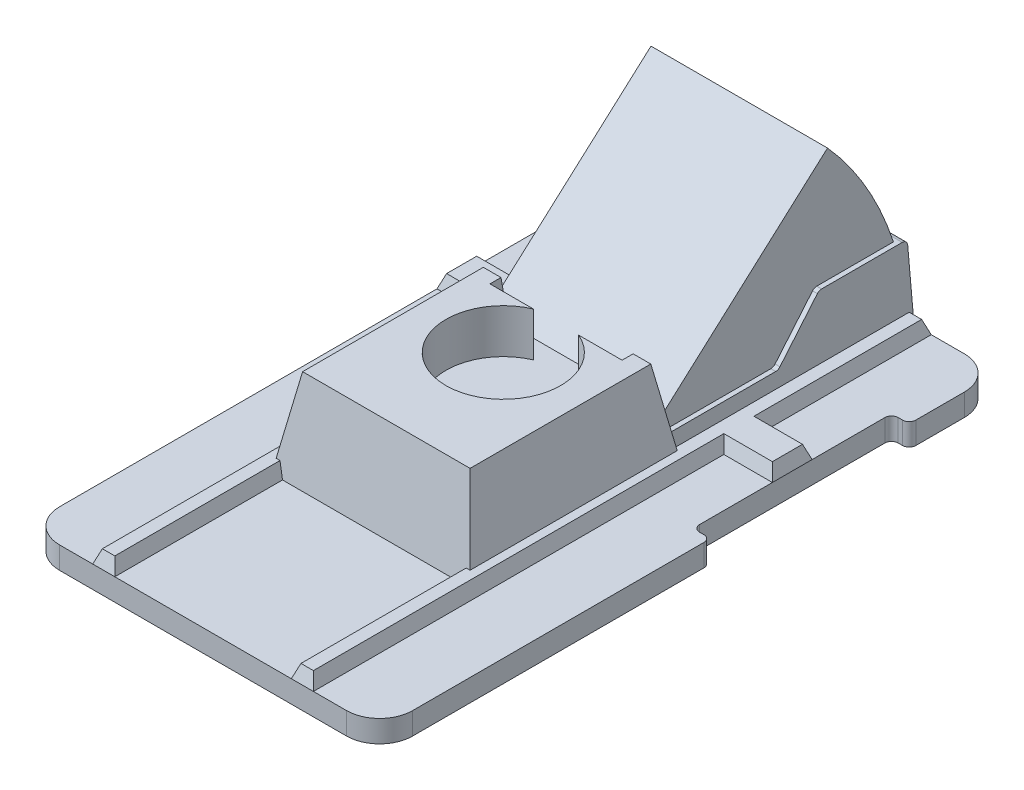
from build123d import *

# Parameters (mm, degrees)
BOSS_EXTRUDE1_DEPTH      = 1
BOSS_EXTRUDE2_DEPTH      = 0.6
BOSS_EXTRUDE2_TAPER      = 20
SKETCH4_W                = 9
SKETCH4_H                = 9.6
BOSS_EXTRUDE3_DEPTH      = 4
BOSS_EXTRUDE3_TAPER      = 10
CUT_EXTRUDE1_DEPTH       = 2
BOSS_EXTRUDE4_DEPTH      = 4
BOSS_EXTRUDE4_DEPTH_BACK = 4
BOSS_EXTRUDE5_DEPTH      = 4.218382
BOSS_EXTRUDE5_DEPTH_BACK = 4.218382
CUT_EXTRUDE2_DEPTH       = 3
CUT_EXTRUDE2_DEPTH_BACK  = 3


with BuildPart() as part:
    # Sketch1 → Boss-Extrude1 (new body)
    with BuildSketch(Plane(origin=(0, 0, 0), x_dir=(1, 0, 0), z_dir=(0, 1, 0))):
        with BuildLine():
            Line((8, 10.3), (8, 12.5))
            ThreePointArc((8, 12.5), (7.560660172, 13.560660172), (6.5, 14))
            Line((6.5, 14), (-6.5, 14))
            ThreePointArc((-6.5, 14), (-7.560660172, 13.560660172), (-8, 12.5))
            Line((-8, 12.5), (-8, -12.5))
            ThreePointArc((-8, -12.5), (-7.560660172, -13.560660172), (-6.5, -14))
            Line((-6.5, -14), (6.5, -14))
            ThreePointArc((6.5, -14), (7.560660172, -13.560660172), (8, -12.5))
            Line((8, -12.5), (8, 0.7))
            ThreePointArc((8, 0.7), (7.912132034, 0.912132034), (7.7, 1))
            Line((7.7, 1), (7.5, 1))
            ThreePointArc((7.5, 1), (7.287867966, 1.087867966), (7.2, 1.3))
            Line((7.2, 1.3), (7.2, 9.7))
            ThreePointArc((7.2, 9.7), (7.287867966, 9.912132034), (7.5, 10))
            Line((7.5, 10), (7.7, 10))
            ThreePointArc((7.7, 10), (7.912132034, 10.087867966), (8, 10.3))
        make_face()
    extrude(amount=BOSS_EXTRUDE1_DEPTH)

    # Sketch2 → Boss-Extrude2 (add)
    with BuildSketch(Plane(origin=(0, 1, 0), x_dir=(1, 0, 0), z_dir=(0, 1, 0))):
        Polygon((-8, 4.6), (-5, 4.6), (-5, -14), (-4, -14), (-4, 4.6), (-4, 6.4), (-4, 14), (-5, 14), (-5, 6.4), (-8, 6.4), align=None)
        Polygon((7.2, 4.6), (7.2, 6.4), (5, 6.4), (5, 14), (4, 14), (4, 6.4), (4, 4.6), (4, -14), (5, -14), (5, 4.6), align=None)
    extrude(amount=BOSS_EXTRUDE2_DEPTH, taper=BOSS_EXTRUDE2_TAPER)

    # Sketch4 → Boss-Extrude3 (add)
    with BuildSketch(Plane(origin=(0, 1, 0), x_dir=(1, 0, 0), z_dir=(0, 1, 0))):
        with Locations((0, -1.6)):
            Rectangle(SKETCH4_W, SKETCH4_H)
    extrude(amount=BOSS_EXTRUDE3_DEPTH, taper=BOSS_EXTRUDE3_TAPER)

    # Sketch5 → Cut-Extrude1 (cut)
    with BuildSketch(Plane(origin=(0, 5, 0), x_dir=(1, 0, 0), z_dir=(0, 1, 0))):
        with BuildLine():
            Line((-2.994692077, 1.994692077), (-1.025106513, 1.994692077))
            ThreePointArc((-1.025106513, 1.994692077), (0, -2.994692077), (1.025106513, 1.994692077))
            Line((1.025106513, 1.994692077), (2.994692077, 1.994692077))
            Line((2.994692077, 1.994692077), (2.994692077, 2.494692077))
            Line((2.994692077, 2.494692077), (2.994692077, 3.2))
            Line((2.994692077, 3.2), (-2.994692077, 3.2))
            Line((-2.994692077, 3.2), (-2.994692077, 2.494692077))
            Line((-2.994692077, 2.494692077), (-2.994692077, 1.994692077))
        make_face()
    extrude(amount=-CUT_EXTRUDE1_DEPTH, mode=Mode.SUBTRACT)

    # Sketch6 → Boss-Extrude4 (add, two sides)
    with BuildSketch(Plane(origin=(0, 0, 0), x_dir=(0, 0, -1), z_dir=(1, 0, 0))) as boss_extrude4_sk:
        with BuildLine():
            Line((-0.5, 0), (10.297970476, 9.67749108))
            ThreePointArc((10.297970476, 9.67749108), (13.042905373, 5.180705941), (14, 0))
            Line((14, 0), (-0.5, 0))
        make_face()
    extrude(amount=BOSS_EXTRUDE4_DEPTH)
    extrude(boss_extrude4_sk.sketch, amount=-BOSS_EXTRUDE4_DEPTH_BACK)

    # Sketch7 → Boss-Extrude5 (add, two sides)
    with BuildSketch(Plane(origin=(0, 0, 0), x_dir=(0, 0, -1), z_dir=(1, 0, 0))) as boss_extrude5_sk:
        with BuildLine():
            Line((2.970774925, 2.3), (7.731260017, 2.3))
            ThreePointArc((7.731260017, 2.3), (7.836854365, 2.323409703), (7.922661977, 2.3892522))
            Line((7.922661977, 2.3892522), (9.61889819, 4.4107478))
            ThreePointArc((9.61889819, 4.4107478), (9.704705802, 4.476590297), (9.81030015, 4.5))
            Line((9.81030015, 4.5), (13.464837448, 4.5))
            ThreePointArc((13.464837448, 4.5), (13.633638738, 4.434356768), (13.713744179, 4.271919003))
            Line((13.713744179, 4.271919003), (14, 1))
            Line((14, 1), (3.2, 1))
            Line((3.2, 1), (2.970774925, 2.3))
        make_face()
    extrude(amount=BOSS_EXTRUDE5_DEPTH)
    extrude(boss_extrude5_sk.sketch, amount=-BOSS_EXTRUDE5_DEPTH_BACK)

    # Sketch9 → Cut-Extrude2 (cut, two sides)
    with BuildSketch(Plane(origin=(0, 0, 0), x_dir=(0, 0, -1), z_dir=(1, 0, 0))) as cut_extrude2_sk:
        with BuildLine():
            ThreePointArc((9.226818428, 4.426818428), (9.30787804, 4.480980729), (9.403494371, 4.5))
            Line((9.403494371, 4.5), (11.8219778, 4.5))
            ThreePointArc((11.8219778, 4.5), (11.97560279, 4.447191058), (12.064288583, 4.311087229))
            ThreePointArc((12.064288583, 4.311087229), (12.315752859, 2.965896786), (12.4, 1.6))
            Line((12.4, 1.6), (12.4, 0))
            Line((12.4, 0), (-5.6, 0))
            Line((-5.6, 0), (-5.6, 1.5781403))
            ThreePointArc((-5.6, 1.5781403), (-5.599049217, 1.599916817), (-5.596204103, 1.621527602))
            Line((-5.596204103, 1.621527602), (-5.495344685, 2.193529787))
            ThreePointArc((-5.495344685, 2.193529787), (-5.409888382, 2.341544446), (-5.249283067, 2.4))
            Line((-5.249283067, 2.4), (-2.562432787, 2.4))
            ThreePointArc((-2.562432787, 2.4), (-2.466816455, 2.380980729), (-2.385756844, 2.326818428))
            Line((-2.385756844, 2.326818428), (-1.732119987, 1.673181572))
            ThreePointArc((-1.732119987, 1.673181572), (-1.651060376, 1.619019271), (-1.555444044, 1.6))
            Line((-1.555444044, 1.6), (6.296505629, 1.6))
            ThreePointArc((6.296505629, 1.6), (6.39212196, 1.619019271), (6.473181572, 1.673181572))
            Line((6.473181572, 1.673181572), (9.226818428, 4.426818428))
        make_face()
    extrude(amount=CUT_EXTRUDE2_DEPTH, mode=Mode.SUBTRACT)
    extrude(cut_extrude2_sk.sketch, amount=-CUT_EXTRUDE2_DEPTH_BACK, mode=Mode.SUBTRACT)


solid = part.part
